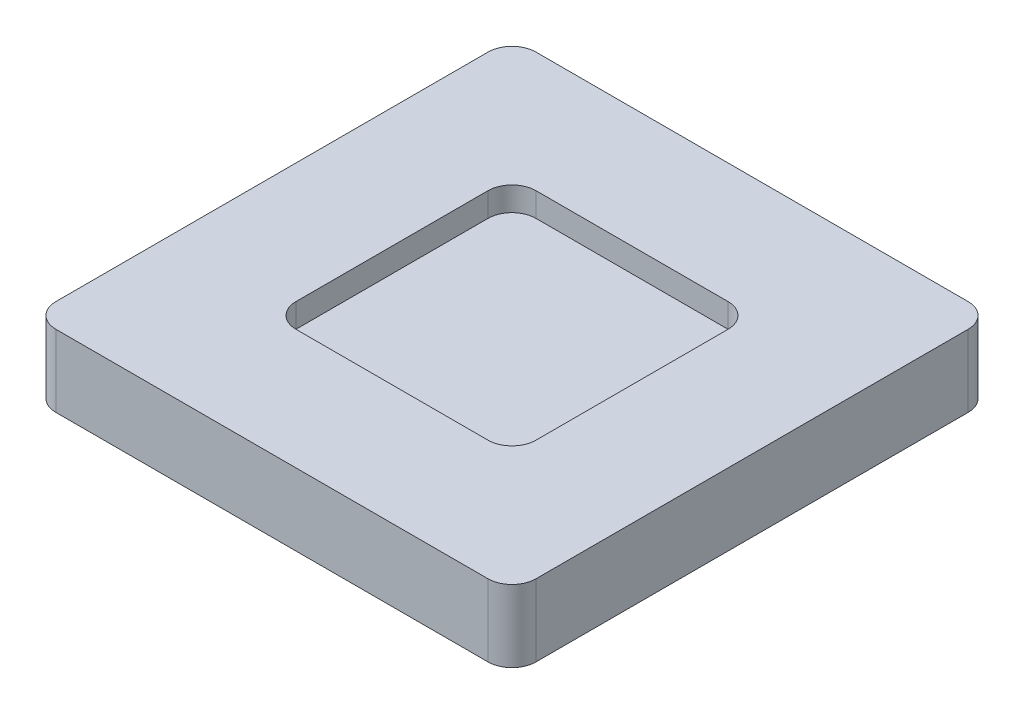
from build123d import *

# Parameters (mm, degrees)
SKETCH1_W           = 20
SKETCH1_H           = 20
BOSS_EXTRUDE1_DEPTH = 3
SKETCH2_W           = 10
SKETCH2_H           = 10
CUT_EXTRUDE1_DEPTH  = 1
FILLET1_R           = 1


with BuildPart() as part:
    # Sketch1 → Boss-Extrude1 (new body)
    with BuildSketch(Plane(origin=(0, 0, 0), x_dir=(1, 0, 0), z_dir=(0, 1, 0))):
        Rectangle(SKETCH1_W, SKETCH1_H)
    extrude(amount=BOSS_EXTRUDE1_DEPTH)

    # Sketch2 → Cut-Extrude1 (cut)
    with BuildSketch(Plane(origin=(0, 3, 0), x_dir=(1, 0, 0), z_dir=(0, 1, 0))):
        Rectangle(SKETCH2_W, SKETCH2_H)
    extrude(amount=-CUT_EXTRUDE1_DEPTH, mode=Mode.SUBTRACT)

    # Fillet1
    fillet1_edges = [part.edges().sort_by_distance(p)[0] for p in [
        (-5, 2.5, 5),
        (-5, 2.5, -5),
        (5, 2.5, -5),
        (5, 2.5, 5),
        (-10, 1.5, -10),
        (10, 1.5, -10),
        (10, 1.5, 10),
        (-10, 1.5, 10),
    ]]
    fillet(fillet1_edges, radius=FILLET1_R)


solid = part.part
